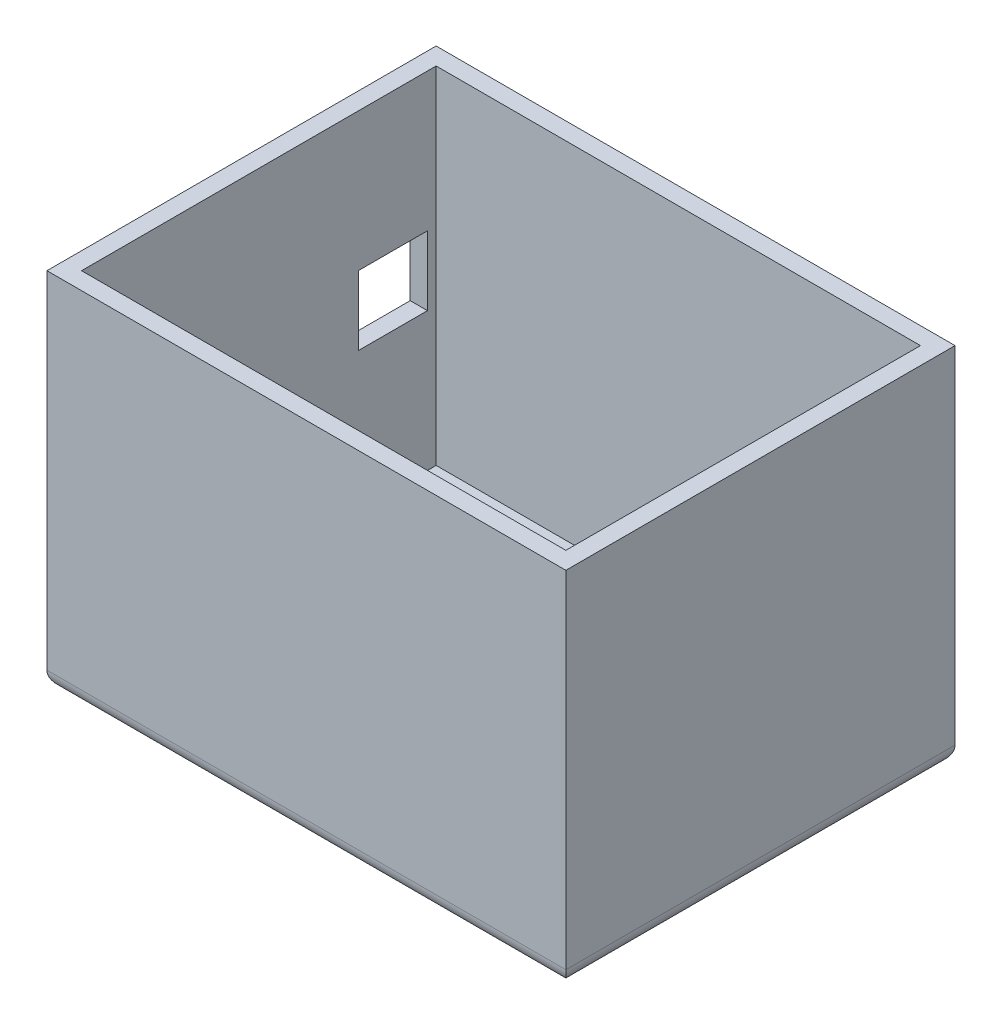
from build123d import *

# Parameters (mm, degrees)
SKETCH1_W           = 600
SKETCH1_H           = 450
SKETCH1_W_2         = 560
SKETCH1_H_2         = 410
BOSS_EXTRUDE1_DEPTH = 400
SKETCH2_W           = 600
SKETCH2_H           = 450
BOSS_EXTRUDE2_DEPTH = 20
FILLET1_R           = 20
SKETCH8_W           = 80
SKETCH8_H           = 80
CUT_EXTRUDE3_DEPTH  = 20


with BuildPart() as part:
    # Sketch1 → Boss-Extrude1 (new body)
    with BuildSketch(Plane(origin=(0, 0, 0), x_dir=(1, 0, 0), z_dir=(0, 1, 0))):
        Rectangle(SKETCH1_W, SKETCH1_H)
        Rectangle(SKETCH1_W_2, SKETCH1_H_2, mode=Mode.SUBTRACT)
    extrude(amount=BOSS_EXTRUDE1_DEPTH)

    # Sketch2 → Boss-Extrude2 (add)
    with BuildSketch(Plane.XZ):
        Rectangle(SKETCH2_W, SKETCH2_H)
    extrude(amount=BOSS_EXTRUDE2_DEPTH)

    # Fillet1
    fillet1_edges = [part.edges().sort_by_distance(p)[0] for p in [
        (300, -20, 0),
        (0, -20, 225),
        (-300, -20, 0),
        (0, -20, -225),
    ]]
    fillet(fillet1_edges, radius=FILLET1_R)

    # Sketch8 → Cut-Extrude3 (cut)
    with BuildSketch(Plane.ZY.offset(300)):
        with Locations((155, 200)):
            Rectangle(SKETCH8_W, SKETCH8_H)
        with Locations((-155, 200)):
            Rectangle(SKETCH8_W, SKETCH8_H)
    extrude(amount=-CUT_EXTRUDE3_DEPTH, mode=Mode.SUBTRACT)


solid = part.part
